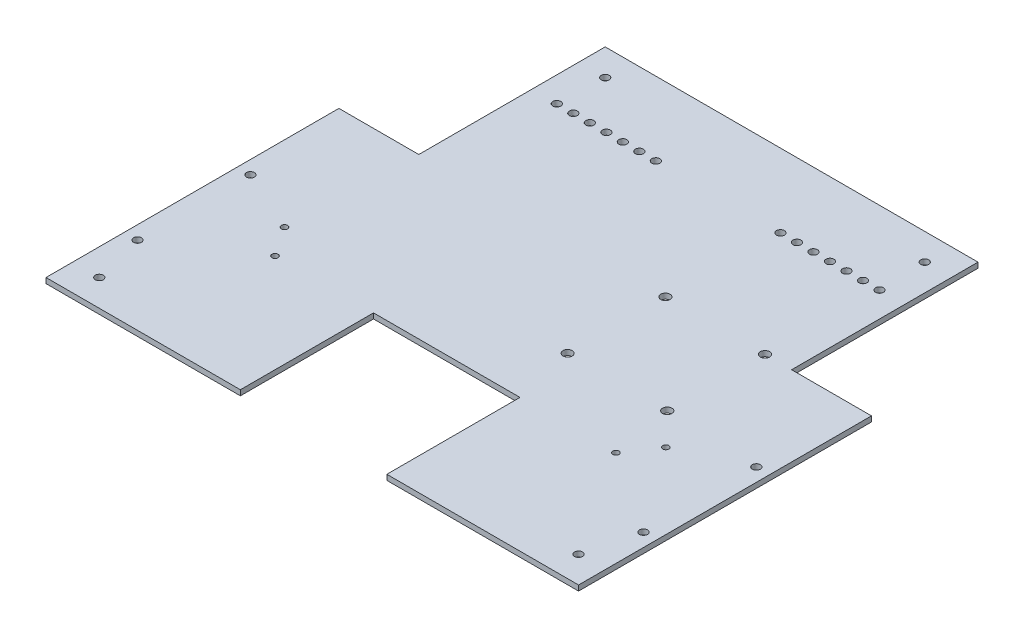
from build123d import *

# Parameters (mm, degrees)
SKETCH1_W           = 200
SKETCH1_H           = 180
BOSS_EXTRUDE1_DEPTH = 2
SKETCH2_W           = 55
SKETCH2_H           = 50
CUT_EXTRUDE1_DEPTH  = 4
SKETCH3_W           = 30
SKETCH3_H           = 70
CUT_EXTRUDE2_DEPTH  = 16
SKETCH4_R           = 1.5
CUT_EXTRUDE3_DEPTH  = 10
SKETCH5_R           = 1.75
CUT_EXTRUDE4_DEPTH  = 10
SKETCH6_R           = 1.5
CUT_EXTRUDE5_DEPTH  = 2
SKETCH7_R           = 1.15
CUT_EXTRUDE6_DEPTH  = 2
SKETCH8_R           = 1.5
CUT_EXTRUDE7_DEPTH  = 2


with BuildPart() as part:
    # Sketch1 → Boss-Extrude1 (new body)
    with BuildSketch(Plane(origin=(0, 0, 0), x_dir=(1, 0, 0), z_dir=(0, 1, 0))):
        Rectangle(SKETCH1_W, SKETCH1_H)
    extrude(amount=BOSS_EXTRUDE1_DEPTH)

    # Sketch2 → Cut-Extrude1 (cut)
    with BuildSketch(Plane(origin=(0, 2, 0), x_dir=(1, 0, 0), z_dir=(0, 1, 0))):
        with Locations((0.5, -65)):
            Rectangle(SKETCH2_W, SKETCH2_H)
    extrude(amount=-CUT_EXTRUDE1_DEPTH, mode=Mode.SUBTRACT)

    # Sketch3 → Cut-Extrude2 (cut)
    with BuildSketch(Plane(origin=(0, 2, 0), x_dir=(1, 0, 0), z_dir=(0, 1, 0))):
        with Locations((85, 55)):
            Rectangle(SKETCH3_W, SKETCH3_H)
        with Locations((-85, 55)):
            Rectangle(SKETCH3_W, SKETCH3_H)
    extrude(amount=-CUT_EXTRUDE2_DEPTH, mode=Mode.SUBTRACT)

    # Sketch4 → Cut-Extrude3 (cut)
    with BuildSketch(Plane(origin=(0, 2, 0), x_dir=(1, 0, 0), z_dir=(0, 1, 0))):
        with Locations((90, -80)):
            Circle(SKETCH4_R)
        with Locations((-90, -80)):
            Circle(SKETCH4_R)
        with Locations((60, 80)):
            Circle(SKETCH4_R)
        with Locations((-60, 80)):
            Circle(SKETCH4_R)
    extrude(amount=-CUT_EXTRUDE3_DEPTH, mode=Mode.SUBTRACT)

    # Sketch5 → Cut-Extrude4 (cut)
    with BuildSketch(Plane(origin=(0, 2, 0), x_dir=(1, 0, 0), z_dir=(0, 1, 0))):
        with Locations((60, 20)):
            Circle(SKETCH5_R)
        with Locations((22.6, 20)):
            Circle(SKETCH5_R)
        with Locations((22.6, -16.7)):
            Circle(SKETCH5_R)
        with Locations((60, -16.7)):
            Circle(SKETCH5_R)
    extrude(amount=-CUT_EXTRUDE4_DEPTH, mode=Mode.SUBTRACT)

    # Sketch6 → Cut-Extrude5 (cut)
    with BuildSketch(Plane(origin=(0, 2, 0), x_dir=(1, 0, 0), z_dir=(0, 1, 0))):
        with Locations((-95, -60.635083269)):
            Circle(SKETCH6_R)
        with Locations((-95, -18.235083269)):
            Circle(SKETCH6_R)
        with Locations((95, -60.635083269)):
            Circle(SKETCH6_R)
        with Locations((95, -18.235083269)):
            Circle(SKETCH6_R)
    extrude(amount=-CUT_EXTRUDE5_DEPTH, mode=Mode.SUBTRACT)

    # Sketch7 → Cut-Extrude6 (cut)
    with BuildSketch(Plane.XZ):
        with Locations((64, 40)):
            Circle(SKETCH7_R)
        with Locations((71.597678191, 28.840910158)):
            Circle(SKETCH7_R)
        with Locations((-64, 40)):
            Circle(SKETCH7_R)
        with Locations((-71.597678191, 28.840910158)):
            Circle(SKETCH7_R)
    extrude(amount=-CUT_EXTRUDE6_DEPTH, mode=Mode.SUBTRACT)

    # Sketch8 → Cut-Extrude7 (cut)
    with BuildSketch(Plane.XZ):
        with Locations((60.59, -62.42)):
            Circle(SKETCH8_R)
        with Locations((54.39, -62.42)):
            Circle(SKETCH8_R)
        with Locations((48.19, -62.42)):
            Circle(SKETCH8_R)
        with Locations((41.99, -62.42)):
            Circle(SKETCH8_R)
        with Locations((35.79, -62.42)):
            Circle(SKETCH8_R)
        with Locations((29.59, -62.42)):
            Circle(SKETCH8_R)
        with Locations((23.39, -62.42)):
            Circle(SKETCH8_R)
        with Locations((-23.39, -62.42)):
            Circle(SKETCH8_R)
        with Locations((-29.59, -62.42)):
            Circle(SKETCH8_R)
        with Locations((-35.79, -62.42)):
            Circle(SKETCH8_R)
        with Locations((-41.99, -62.42)):
            Circle(SKETCH8_R)
        with Locations((-60.59, -62.42)):
            Circle(SKETCH8_R)
        with Locations((-54.39, -62.42)):
            Circle(SKETCH8_R)
        with Locations((-48.19, -62.42)):
            Circle(SKETCH8_R)
    extrude(amount=-CUT_EXTRUDE7_DEPTH, mode=Mode.SUBTRACT)


solid = part.part
